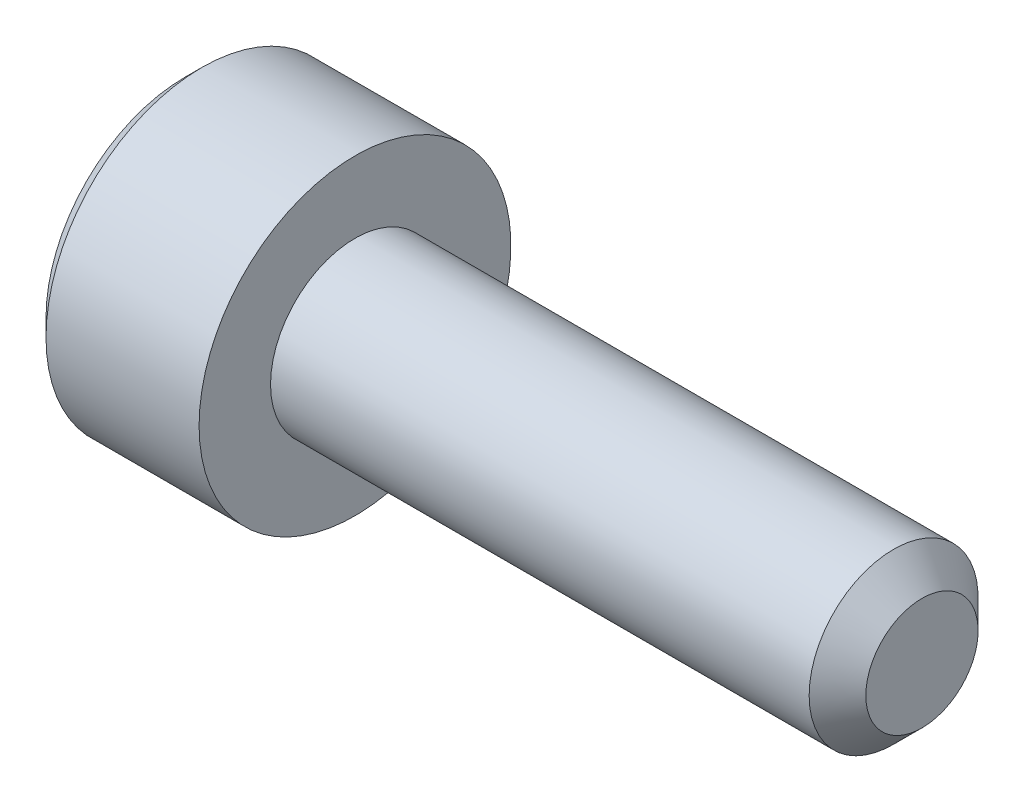
from build123d import *

# Parameters (mm, degrees)
CHAMFER1_SIZE      = 0.5
CHAMFER2_SIZE      = 0.3
CUT_EXTRUDE1_DEPTH = 2.5
CHAMFER3_SIZE      = 0.3


with BuildPart() as part:
    # Sketch1 → Revolve1 (revolve)
    with BuildSketch(Plane.XY):
        Polygon((0, 0), (0, 2.75), (3, 2.75), (3, 1.49), (13, 1.49), (13, 0), align=None)
    revolve(axis=Axis((-88.705490849, 0, 0), (1, 0, 0)))

    # Chamfer1
    chamfer1_edges = [part.edges().sort_by_distance(p)[0] for p in [
        (13, -1.49, 0),
    ]]
    chamfer(chamfer1_edges, length=CHAMFER1_SIZE)

    # Chamfer2
    chamfer2_edges = [part.edges().sort_by_distance(p)[0] for p in [
        (0, -2.75, 0),
    ]]
    chamfer(chamfer2_edges, length=CHAMFER2_SIZE)

    # Sketch3 → Cut-Extrude1 (cut)
    with BuildSketch(Plane(origin=(0, 0, 0), x_dir=(0, 0, -1), z_dir=(1, 0, 0))):
        Polygon((-1.443375673, 0), (-0.721687836, -1.25), (0.721687836, -1.25), (1.443375673, 0), (0.721687836, 1.25), (-0.721687836, 1.25), align=None)
    extrude(amount=CUT_EXTRUDE1_DEPTH, mode=Mode.SUBTRACT)

    # Chamfer3
    chamfer3_edges = [part.edges().sort_by_distance(p)[0] for p in [
        (0, 1.25, 0),
        (0, 0.625, 1.082531755),
        (0, -0.625, 1.082531755),
        (0, -1.25, 0),
        (0, -0.625, -1.082531755),
        (0, 0.625, -1.082531755),
    ]]
    chamfer(chamfer3_edges, length=CHAMFER3_SIZE)


solid = part.part
